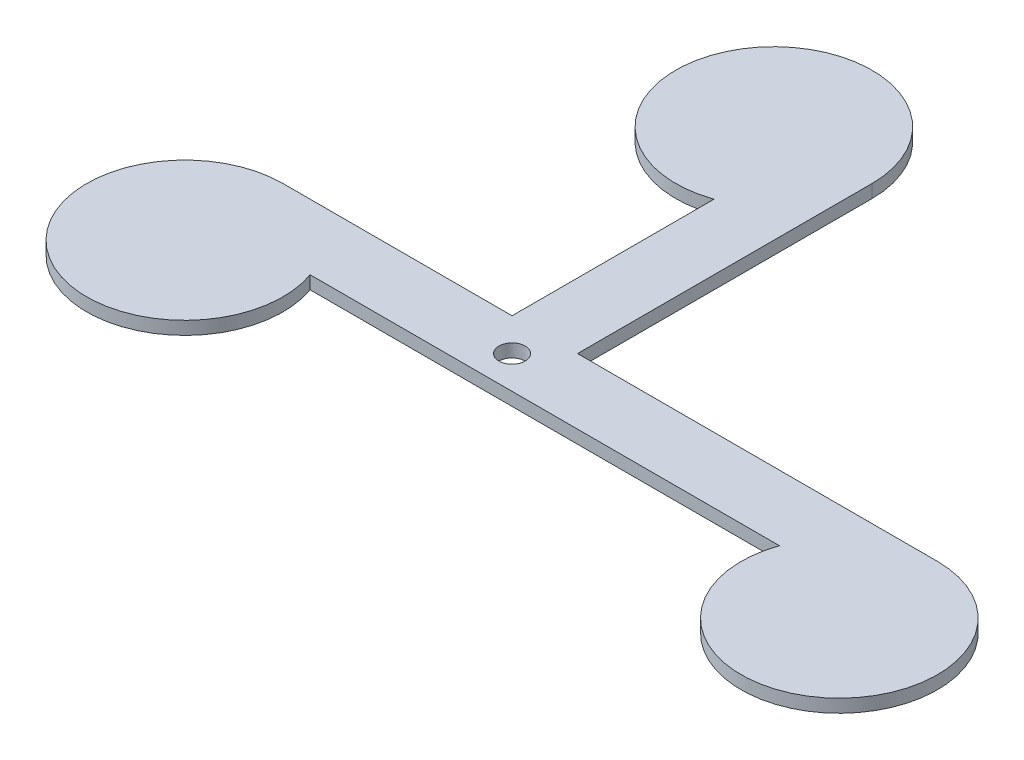
from build123d import *

# Parameters (mm, degrees)
BASEEXTRUDE_DEPTH   = 2
SKETCH1_R           = 2
CUT_EXTRUDE1_DEPTH  = 3
SKETCH2_R           = 2.45
BOSS_EXTRUDE1_DEPTH = 2
FILLET1_R           = 1


with BuildPart() as part:
    # BaseSketch → BaseExtrude (new body)
    with BuildSketch(Plane(origin=(0, 0, 0), x_dir=(1, 0, 0), z_dir=(0, 1, 0))):
        with BuildLine():
            Line((35, 15), (0, 15))
            ThreePointArc((0, 15), (-8.660254038, -12.247448714), (14.142135624, 5))
            Line((14.142135624, 5), (45, 5))
            Line((45, 5), (85.857864376, 5))
            ThreePointArc((85.857864376, 5), (108.660254038, -12.247448714), (100, 15))
            Line((100, 15), (45, 15))
            Line((45, 15), (45, 60))
            ThreePointArc((45, 60), (17.752551286, 68.660254038), (35, 45.857864376))
            Line((35, 45.857864376), (35, 15))
        make_face()
    extrude(amount=BASEEXTRUDE_DEPTH)

    # Sketch1 → Cut-Extrude1 (cut, through all)
    with BuildSketch(Plane.XZ):
        with Locations((40, -10)):
            Circle(SKETCH1_R)
    extrude(amount=-CUT_EXTRUDE1_DEPTH, mode=Mode.SUBTRACT)

    # Sketch2 → Boss-Extrude1 (add)
    with BuildSketch(Plane.XZ):
        with Locations((40, -16.5)):
            Circle(SKETCH2_R)
    extrude(amount=BOSS_EXTRUDE1_DEPTH)

    # Fillet1
    fillet1_edges = [part.edges().sort_by_distance(p)[0] for p in [
        (37.55, -2, -16.5),
    ]]
    fillet(fillet1_edges, radius=FILLET1_R)


solid = part.part
